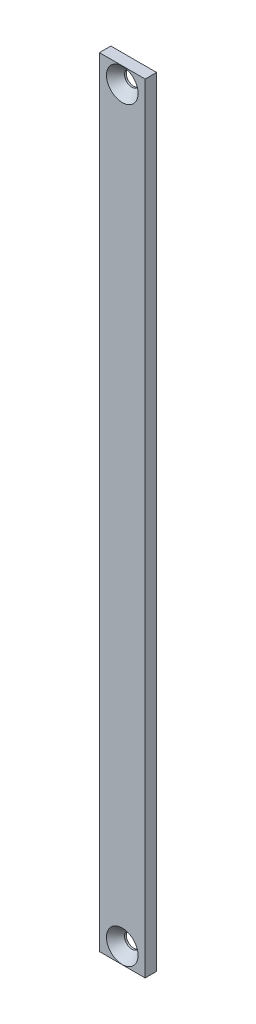
from build123d import *

# Parameters (mm, degrees)
SKETCH1_W                                    = 25.4
SKETCH1_H                                    = 431.973597558
EXTRUDE1_DEPTH                               = 6.35
CSK_FOR_5_16_FLAT_HEAD_SOCKET_CAP_SC_2_COUNT = 2
CSK_FOR_5_16_FLAT_HEAD_SOCKET_CAP_SC_2_PITCH = 414.193597559


with BuildPart() as part:
    # Sketch1 → Extrude1 (new body)
    with BuildSketch(Plane.XY):
        with Locations((-41.434947789, 0)):
            Rectangle(SKETCH1_W, SKETCH1_H)
    extrude(amount=EXTRUDE1_DEPTH)

    # Sketch4 → CSK for 5/16 Flat Head Socket Cap Screw1 (revolve, cut)
    with BuildSketch(Plane(origin=(-41.434947789, 207.096798779, 6.35), x_dir=(0, -1, 0), z_dir=(1, 0, 0))):
        Polygon((0, 0), (0, 6.35), (4.1021, 6.35), (4.1021, 5.373016172), (8.7727917, 0), align=None)
    csk_for_5_16_flat_head_socket_cap_screw1 = revolve(axis=Axis((-41.434947789, 207.096798779, 12.7), (0, 0, -1)), mode=Mode.SUBTRACT)

    # CSK for 5_16 Flat Head Socket Cap Sc 2: CSK for 5/16 Flat Head Socket Cap Screw1 ×2
    with Locations(*[(0, -i * CSK_FOR_5_16_FLAT_HEAD_SOCKET_CAP_SC_2_PITCH, 0) for i in range(1, CSK_FOR_5_16_FLAT_HEAD_SOCKET_CAP_SC_2_COUNT)]):
        add(csk_for_5_16_flat_head_socket_cap_screw1, mode=Mode.SUBTRACT)


solid = part.part
